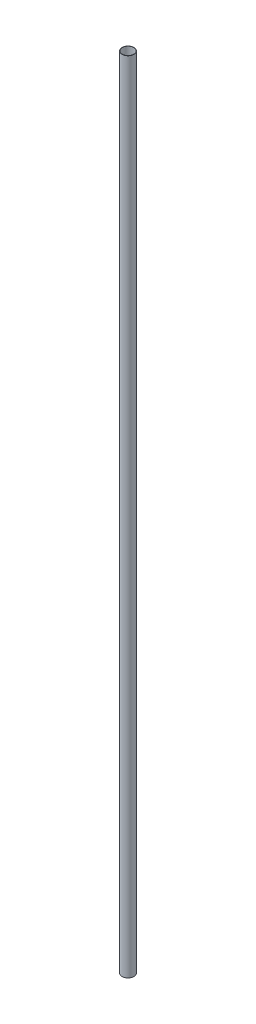
from build123d import *

# Parameters (mm, degrees)
SKETCH1_R           = 15
SKETCH1_R_2         = 14.434968314
BOSS_EXTRUDE2_DEPTH = 2000


with BuildPart() as part:
    # Sketch1 → Boss-Extrude2 (new body)
    with BuildSketch(Plane(origin=(0, 0, 0), x_dir=(1, 0, 0), z_dir=(0, 1, 0))):
        Circle(SKETCH1_R)
        Circle(SKETCH1_R_2, mode=Mode.SUBTRACT)
    extrude(amount=BOSS_EXTRUDE2_DEPTH)


solid = part.part
